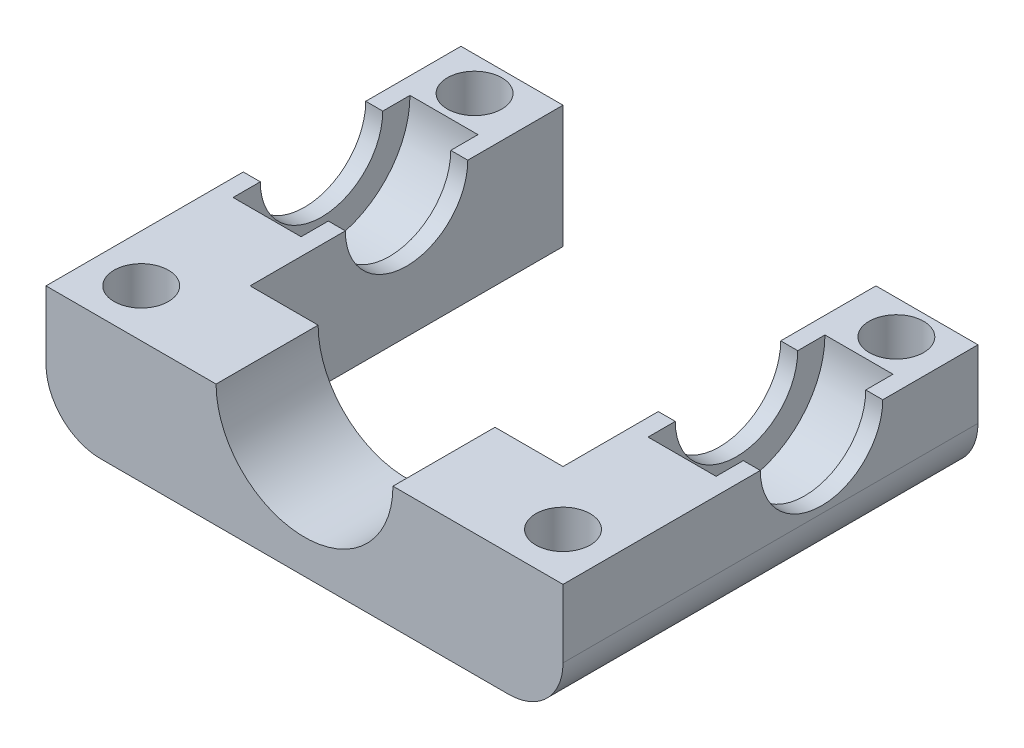
from build123d import *

# Parameters (mm, degrees)
BOSS_EXTRUDE1_DEPTH     = 9
SKETCH2_R               = 6.5
CUT_EXTRUDE1_DEPTH      = 2.5
SKETCH3_R               = 4.5
CUT_EXTRUDE2_DEPTH      = 20
FILLET1_R               = 4
SKETCH4_R               = 6.5
CUT_EXTRUDE3_DEPTH      = 20
CUT_EXTRUDE3_DEPTH_BACK = 12.5
SKETCH6_R               = 2
CUT_EXTRUDE4_DEPTH      = 10


with BuildPart() as part:
    # Sketch1 → Boss-Extrude1 (new body)
    with BuildSketch(Plane(origin=(0, 0, 0), x_dir=(1, 0, 0), z_dir=(0, 1, 0))):
        Polygon((-19, 11.5), (-19, -19), (19, -19), (19, 11.5), (11.5, 11.5), (11.5, -11.5), (-11.5, -11.5), (-11.5, 11.5), align=None)
    extrude(amount=BOSS_EXTRUDE1_DEPTH)

    # Sketch2 → Cut-Extrude1 (cut, symmetric)
    with BuildSketch(Plane(origin=(15.25, 0, 0), x_dir=(0, 0, -1), z_dir=(1, 0, 0))):
        with Locations((0, 9)):
            Circle(SKETCH2_R)
    cut_extrude1 = extrude(amount=CUT_EXTRUDE1_DEPTH, both=True, mode=Mode.SUBTRACT)

    # Sketch3 → Cut-Extrude2 (cut, through all)
    with BuildSketch(Plane(origin=(0, 0, 0), x_dir=(0, 0, -1), z_dir=(1, 0, 0))):
        with Locations((0, 9)):
            Circle(SKETCH3_R)
    cut_extrude2 = extrude(amount=CUT_EXTRUDE2_DEPTH, mode=Mode.SUBTRACT)

    # Mirror1: Cut-Extrude1, Cut-Extrude2 across plane
    add(cut_extrude1.mirror(Plane(origin=(0, 0, 0), x_dir=(0, 0, 1), z_dir=(1, 0, 0))), mode=Mode.SUBTRACT)
    add(cut_extrude2.mirror(Plane(origin=(0, 0, 0), x_dir=(0, 0, 1), z_dir=(1, 0, 0))), mode=Mode.SUBTRACT)

    # Fillet1
    fillet1_edges = [part.edges().sort_by_distance(p)[0] for p in [
        (19, 0, 3.75),
        (-19, 0, 3.75),
    ]]
    fillet(fillet1_edges, radius=FILLET1_R)

    # Sketch4 → Cut-Extrude3 (cut, two sides)
    with BuildSketch(Plane.XY) as cut_extrude3_sk:
        with Locations((0, 9)):
            Circle(SKETCH4_R)
    extrude(amount=CUT_EXTRUDE3_DEPTH, mode=Mode.SUBTRACT)
    extrude(cut_extrude3_sk.sketch, amount=-CUT_EXTRUDE3_DEPTH_BACK, mode=Mode.SUBTRACT)

    # Sketch6 → Cut-Extrude4 (cut, through all)
    with BuildSketch(Plane(origin=(0, 9, 0), x_dir=(1, 0, 0), z_dir=(0, 1, 0))):
        with Locations((-15.5, 9)):
            Circle(SKETCH6_R)
        with Locations((15.5, 9)):
            Circle(SKETCH6_R)
        with Locations((15.5, -15.5)):
            Circle(SKETCH6_R)
        with Locations((-15.5, -15.5)):
            Circle(SKETCH6_R)
    extrude(amount=-CUT_EXTRUDE4_DEPTH, mode=Mode.SUBTRACT)


solid = part.part
